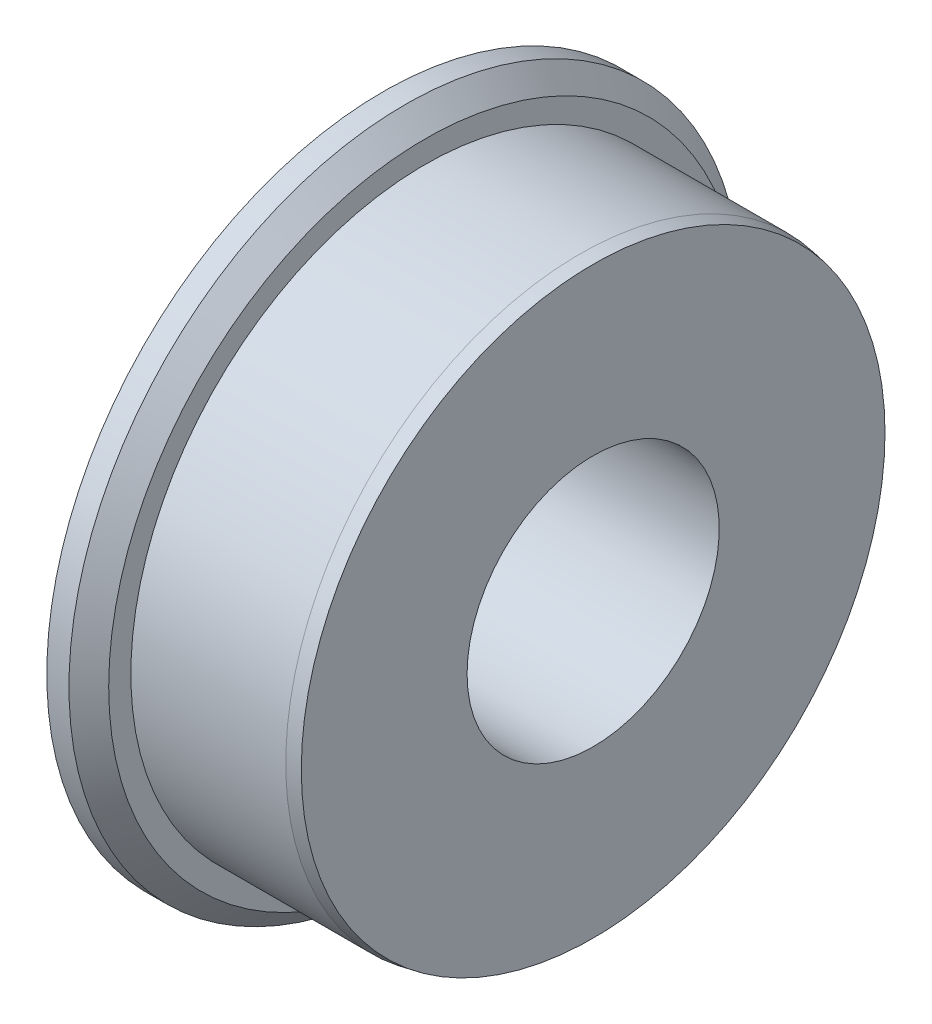
from build123d import *

# Parameters (mm, degrees)
SKETCH1_R           = 25.4
BOSS_EXTRUDE1_DEPTH = 3.175
SKETCH2_R           = 22.225
BOSS_EXTRUDE2_DEPTH = 12.7
SKETCH3_R           = 9.525
CUT_EXTRUDE1_DEPTH  = 16.875
CHAMFER1_SIZE       = 1
CHAMFER1_SIZE2      = 0.176326981
CHAMFER2_SIZE       = 1.5


with BuildPart() as part:
    # Sketch1 → Boss-Extrude1 (new body)
    with BuildSketch(Plane(origin=(0, 0, 0), x_dir=(0, 0, -1), z_dir=(1, 0, 0))):
        Circle(SKETCH1_R)
    extrude(amount=BOSS_EXTRUDE1_DEPTH)

    # Sketch2 → Boss-Extrude2 (add)
    with BuildSketch(Plane(origin=(3.175, 0, 0), x_dir=(0, 0, -1), z_dir=(1, 0, 0))):
        Circle(SKETCH2_R)
    extrude(amount=BOSS_EXTRUDE2_DEPTH)

    # Sketch3 → Cut-Extrude1 (cut, through all)
    with BuildSketch(Plane.ZY):
        Circle(SKETCH3_R)
    extrude(amount=-CUT_EXTRUDE1_DEPTH, mode=Mode.SUBTRACT)

    # Chamfer1
    chamfer1_edges = [part.edges().sort_by_distance(p)[0] for p in [
        (15.875, 0, 22.225),
    ]]
    chamfer1_side = [part.faces().sort_by_distance(p)[0] for p in [
        (9.525, 0, 22.225),
    ]]
    chamfer(chamfer1_edges, length=CHAMFER1_SIZE, length2=CHAMFER1_SIZE2, reference=chamfer1_side[0])

    # Chamfer2
    chamfer2_edges = [part.edges().sort_by_distance(p)[0] for p in [
        (3.175, 0, 25.4),
    ]]
    chamfer(chamfer2_edges, length=CHAMFER2_SIZE)


solid = part.part
